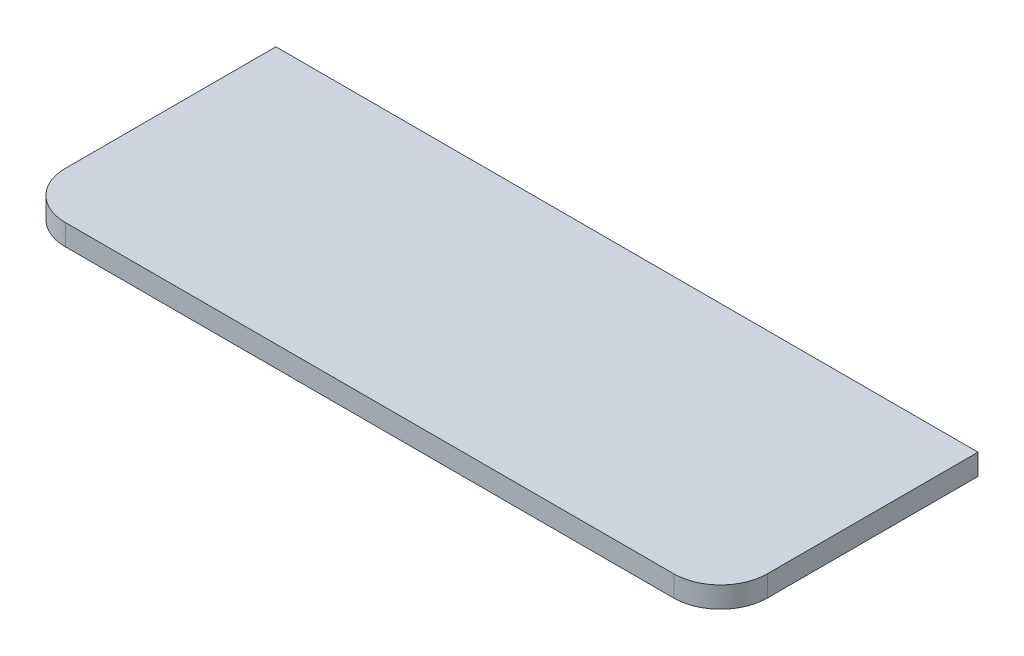
from build123d import *

# Parameters (mm, degrees)
EXTRUDE_1_DEPTH = 18


with BuildPart() as part:
    # Эскиз1 → Бобышка-Вытянуть1 (new body)
    with BuildSketch(Plane(origin=(0, 0, 0), x_dir=(1, 0, 0), z_dir=(0, 1, 0))):
        with BuildLine():
            Line((-32.654939879, 18.151418416), (567.345060121, 18.151418416))
            Line((567.345060121, 18.151418416), (567.345060121, -161.848581584))
            ThreePointArc((567.345060121, -161.848581584), (555.629331369, -190.132852832), (527.345060121, -201.848581584))
            Line((527.345060121, -201.848581584), (7.345060121, -201.848581584))
            ThreePointArc((7.345060121, -201.848581584), (-20.939211126, -190.132852832), (-32.654939879, -161.848581584))
            Line((-32.654939879, -161.848581584), (-32.654939879, 18.151418416))
        make_face()
    extrude(amount=EXTRUDE_1_DEPTH)


solid = part.part
